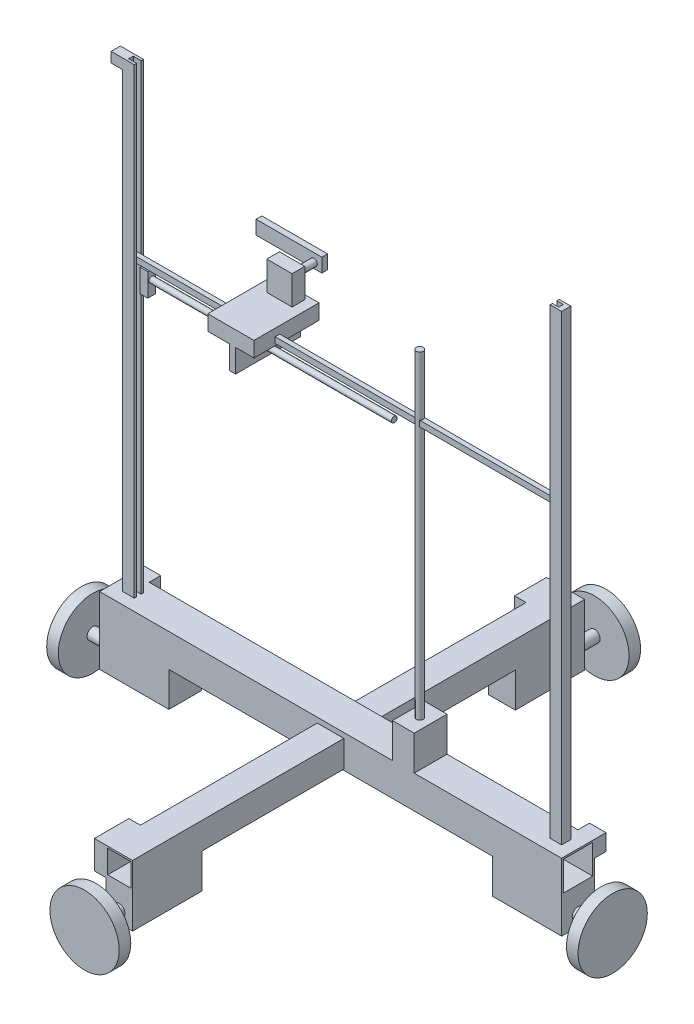
from build123d import *

# Parameters (mm, degrees)
SKETCH1_W                = 28.4
SKETCH1_H                = 28.4
SKETCH1_W_2              = 25.4
SKETCH1_H_2              = 25.4
EXTRUDE_THIN1_DEPTH      = 400
SKETCH2_W                = 23
SKETCH2_H                = 23
SKETCH2_W_2              = 20
SKETCH2_H_2              = 20
EXTRUDE_THIN2_DEPTH      = 183
EXTRUDE_THIN2_DEPTH_BACK = 208.4
SKETCH3_W                = 60
SKETCH3_H                = 28.4
BOSS_EXTRUDE1_DEPTH      = 30
SKETCH4_W                = 23
SKETCH4_H                = 60
BOSS_EXTRUDE2_DEPTH      = 30
SKETCH5_R                = 5
BOSS_EXTRUDE3_DEPTH      = 30
SKETCH6_R                = 5
BOSS_EXTRUDE4_DEPTH      = 30
SKETCH7_R                = 5
BOSS_EXTRUDE5_DEPTH      = 30
SKETCH8_R                = 5
BOSS_EXTRUDE6_DEPTH      = 30
BOSS_EXTRUDE7_DEPTH      = 400
SKETCH10_W               = 372.349277715
SKETCH10_H               = 4
BOSS_EXTRUDE8_DEPTH      = 5
SKETCH24_R               = 30
BOSS_EXTRUDE20_DEPTH     = 10
SKETCH25_R               = 30
BOSS_EXTRUDE21_DEPTH     = 10
SKETCH26_R               = 30
BOSS_EXTRUDE22_DEPTH     = 10
SKETCH27_R               = 30
BOSS_EXTRUDE23_DEPTH     = 10
SKETCH28_W               = 18.859227369
SKETCH28_H               = 28.4
BOSS_EXTRUDE24_DEPTH     = 30
SKETCH29_R               = 3
BOSS_EXTRUDE25_DEPTH     = 276
SKETCH30_W               = 56.280454212
SKETCH30_H               = 13.197921903
BOSS_EXTRUDE26_DEPTH     = 40
SKETCH31_W               = 6.795939819
SKETCH31_H               = 6.783661409
BOSS_EXTRUDE27_DEPTH     = 20
SKETCH32_R               = 2.5
BOSS_EXTRUDE28_DEPTH     = 210
SKETCH33_W               = 5.188291065
SKETCH33_H               = 56.280454212
BOSS_EXTRUDE29_DEPTH     = 20
SKETCH34_W               = 21.924689073
SKETCH34_H               = 10.967349769
BOSS_EXTRUDE30_DEPTH     = 25
SKETCH35_R               = 3
BOSS_EXTRUDE31_DEPTH     = 20
SKETCH36_W               = 56.888194478
SKETCH36_H               = 11.912179608
BOSS_EXTRUDE32_DEPTH     = 5
SKETCH37_W               = 8
SKETCH37_H               = 8.77554695
BOSS_EXTRUDE33_DEPTH     = 10
SKETCH38_W               = 27.606480259
SKETCH38_H               = 24.3695053
SKETCH38_W_2             = 29.861732126
BOSS_EXTRUDE34_DEPTH     = 10
SKETCH39_W               = 14.536900962
SKETCH39_H               = 18.409696894
SKETCH39_W_2             = 14.264364069
SKETCH39_H_2             = 14.2
BOSS_EXTRUDE35_DEPTH     = 10


with BuildPart() as part:
    # Sketch1 → Extrude-Thin1 (new body)
    with BuildSketch(Plane(origin=(0, 0, 0), x_dir=(0, 0, -1), z_dir=(1, 0, 0))):
        Rectangle(SKETCH1_W, SKETCH1_H)
        Rectangle(SKETCH1_W_2, SKETCH1_H_2, mode=Mode.SUBTRACT)
    extrude(amount=EXTRUDE_THIN1_DEPTH)

    # Sketch2 → Extrude-Thin2 (add, two sides)
    with BuildSketch(Plane.XY.offset(14.2)) as extrude_thin2_sk:
        with Locations((200, -1.693644648)):
            Rectangle(SKETCH2_W, SKETCH2_H)
        with Locations((200, -1.693644648)):
            Rectangle(SKETCH2_W_2, SKETCH2_H_2, mode=Mode.SUBTRACT)
    extrude(amount=EXTRUDE_THIN2_DEPTH)
    extrude(extrude_thin2_sk.sketch, amount=-EXTRUDE_THIN2_DEPTH_BACK)

    # Sketch3 → Boss-Extrude1 (add)
    with BuildSketch(Plane(origin=(0, -14.2, 0), x_dir=(-1, 0, 0), z_dir=(0, -1, 0))):
        with Locations((-370, 0)):
            Rectangle(SKETCH3_W, SKETCH3_H)
        with Locations((-30, 0)):
            Rectangle(SKETCH3_W, SKETCH3_H)
    extrude(amount=BOSS_EXTRUDE1_DEPTH)

    # Sketch4 → Boss-Extrude2 (add)
    with BuildSketch(Plane(origin=(0, -13.193644648, 0), x_dir=(-1, 0, 0), z_dir=(0, -1, 0))):
        with Locations((-200, -167.2)):
            Rectangle(SKETCH4_W, SKETCH4_H)
        with Locations((-200, 164.2)):
            Rectangle(SKETCH4_W, SKETCH4_H)
    extrude(amount=BOSS_EXTRUDE2_DEPTH)

    # Sketch5 → Boss-Extrude3 (add)
    with BuildSketch(Plane(origin=(400, 0, 0), x_dir=(0, 0, -1), z_dir=(1, 0, 0))):
        with Locations((0, -34.2)):
            Circle(SKETCH5_R)
    extrude(amount=BOSS_EXTRUDE3_DEPTH)

    # Sketch6 → Boss-Extrude4 (add)
    with BuildSketch(Plane(origin=(0, 0, -194.2), x_dir=(-1, 0, 0), z_dir=(0, 0, -1))):
        with Locations((-200, -33.193644648)):
            Circle(SKETCH6_R)
    extrude(amount=BOSS_EXTRUDE4_DEPTH)

    # Sketch7 → Boss-Extrude5 (add)
    with BuildSketch(Plane.ZY):
        with Locations((0, -34.2)):
            Circle(SKETCH7_R)
    extrude(amount=BOSS_EXTRUDE5_DEPTH)

    # Sketch8 → Boss-Extrude6 (add)
    with BuildSketch(Plane.XY.offset(197.2)):
        with Locations((200, -33.193644648)):
            Circle(SKETCH8_R)
    extrude(amount=BOSS_EXTRUDE6_DEPTH)

    # Sketch9 → Boss-Extrude7 (add)
    with BuildSketch(Plane(origin=(0, 14.2, 0), x_dir=(1, 0, 0), z_dir=(0, 1, 0))):
        Polygon((10, 3.8), (20, 3.8), (20, 1.8), (13.177515759, 1.8), (13.177515759, -2.2), (20, -2.2), (20, -4.2), (10, -4.2), align=None)
        Polygon((380, 3.8), (390, 3.8), (390, -4.2), (380, -4.2), (380, -2.2), (385.526793474, -2.2), (385.526793474, 1.8), (380, 1.8), align=None)
    extrude(amount=BOSS_EXTRUDE7_DEPTH)

    # Sketch10 → Boss-Extrude8 (add)
    with BuildSketch(Plane(origin=(0, 264.2, 0), x_dir=(1, 0, 0), z_dir=(0, 1, 0))):
        with Locations((199.352154617, -0.2)):
            Rectangle(SKETCH10_W, SKETCH10_H)
    extrude(amount=BOSS_EXTRUDE8_DEPTH)

    # Sketch24 → Boss-Extrude20 (add)
    with BuildSketch(Plane(origin=(0, 0, -224.2), x_dir=(-1, 0, 0), z_dir=(0, 0, -1))):
        with Locations((-200, -33.193644648)):
            Circle(SKETCH24_R)
    extrude(amount=-BOSS_EXTRUDE20_DEPTH)

    # Sketch25 → Boss-Extrude21 (add)
    with BuildSketch(Plane.ZY.offset(30)):
        with Locations((0, -34.2)):
            Circle(SKETCH25_R)
    extrude(amount=-BOSS_EXTRUDE21_DEPTH)

    # Sketch26 → Boss-Extrude22 (add)
    with BuildSketch(Plane.XY.offset(227.2)):
        with Locations((200, -33.193644648)):
            Circle(SKETCH26_R)
    extrude(amount=-BOSS_EXTRUDE22_DEPTH)

    # Sketch27 → Boss-Extrude23 (add)
    with BuildSketch(Plane(origin=(430, 0, 0), x_dir=(0, 0, -1), z_dir=(1, 0, 0))):
        with Locations((0, -34.2)):
            Circle(SKETCH27_R)
    extrude(amount=-BOSS_EXTRUDE23_DEPTH)

    # Sketch28 → Boss-Extrude24 (add)
    with BuildSketch(Plane(origin=(0, 14.2, 0), x_dir=(1, 0, 0), z_dir=(0, 1, 0))):
        with Locations((262.964436909, 0)):
            Rectangle(SKETCH28_W, SKETCH28_H)
    extrude(amount=BOSS_EXTRUDE24_DEPTH)

    # Sketch29 → Boss-Extrude25 (add)
    with BuildSketch(Plane(origin=(0, 44.2, 0), x_dir=(1, 0, 0), z_dir=(0, 1, 0))):
        with Locations((262.978152894, 0)):
            Circle(SKETCH29_R)
    extrude(amount=BOSS_EXTRUDE25_DEPTH)

    # Sketch30 → Boss-Extrude26 (add)
    with BuildSketch(Plane(origin=(100, 0, 0), x_dir=(0, 0, -1), z_dir=(1, 0, 0))):
        with Locations((7.595285017, 269.051232914)):
            Rectangle(SKETCH30_W, SKETCH30_H)
    extrude(amount=BOSS_EXTRUDE26_DEPTH)

    # Sketch31 → Boss-Extrude27 (add)
    with BuildSketch(Plane(origin=(0, 264.2, 0), x_dir=(-1, 0, 0), z_dir=(0, -1, 0))):
        with Locations((-27.594001553, -0.077336563)):
            Rectangle(SKETCH31_W, SKETCH31_H)
    extrude(amount=BOSS_EXTRUDE27_DEPTH)

    # Sketch32 → Boss-Extrude28 (add)
    with BuildSketch(Plane(origin=(30.991971462, 0, 0), x_dir=(0, 0, -1), z_dir=(1, 0, 0))):
        with Locations((0, 256.564095002)):
            Circle(SKETCH32_R)
    extrude(amount=BOSS_EXTRUDE28_DEPTH)

    # Sketch33 → Boss-Extrude29 (add)
    with BuildSketch(Plane(origin=(0, 262.452271962, 0), x_dir=(-1, 0, 0), z_dir=(0, -1, 0))):
        with Locations((-121.53991064, 7.595285017)):
            Rectangle(SKETCH33_W, SKETCH33_H)
    extrude(amount=BOSS_EXTRUDE29_DEPTH)

    # Sketch34 → Boss-Extrude30 (add)
    with BuildSketch(Plane(origin=(0, 275.650193865, 0), x_dir=(1, 0, 0), z_dir=(0, 1, 0))):
        with Locations((120.531111369, 26.453283936)):
            Rectangle(SKETCH34_W, SKETCH34_H)
    extrude(amount=BOSS_EXTRUDE30_DEPTH)

    # Sketch35 → Boss-Extrude31 (add)
    with BuildSketch(Plane(origin=(0, 0, -31.93695882), x_dir=(-1, 0, 0), z_dir=(0, 0, -1))):
        with Locations((-119.378398528, 287.680723614)):
            Circle(SKETCH35_R)
    extrude(amount=BOSS_EXTRUDE31_DEPTH)

    # Sketch36 → Boss-Extrude32 (add)
    with BuildSketch(Plane(origin=(0, 0, -51.93695882), x_dir=(-1, 0, 0), z_dir=(0, 0, -1))):
        with Locations((-97.822495767, 288.961624672)):
            Rectangle(SKETCH36_W, SKETCH36_H)
    extrude(amount=BOSS_EXTRUDE32_DEPTH)

    # Sketch37 → Boss-Extrude33 (add)
    with BuildSketch(Plane.ZY.offset(-10)):
        with Locations((0.2, 409.812226525)):
            Rectangle(SKETCH37_W, SKETCH37_H)
    extrude(amount=BOSS_EXTRUDE33_DEPTH)

    # Sketch38 → Boss-Extrude34 (add)
    with BuildSketch(Plane.ZY.offset(-188.5)):
        with Locations((-180.396759871, -2.378397298)):
            Rectangle(SKETCH38_W, SKETCH38_H)
        with Locations((182.269133937, -2.378397298)):
            Rectangle(SKETCH38_W_2, SKETCH38_H)
    extrude(amount=BOSS_EXTRUDE34_DEPTH)

    # Sketch39 → Boss-Extrude35 (add)
    with BuildSketch(Plane(origin=(0, 0, -14.2), x_dir=(-1, 0, 0), z_dir=(0, 0, -1))):
        with Locations((-7.268450481, 4.995151553)):
            Rectangle(SKETCH39_W, SKETCH39_H)
        with Locations((-392.867817966, 7.1)):
            Rectangle(SKETCH39_W_2, SKETCH39_H_2)
    extrude(amount=BOSS_EXTRUDE35_DEPTH)


solid = part.part
